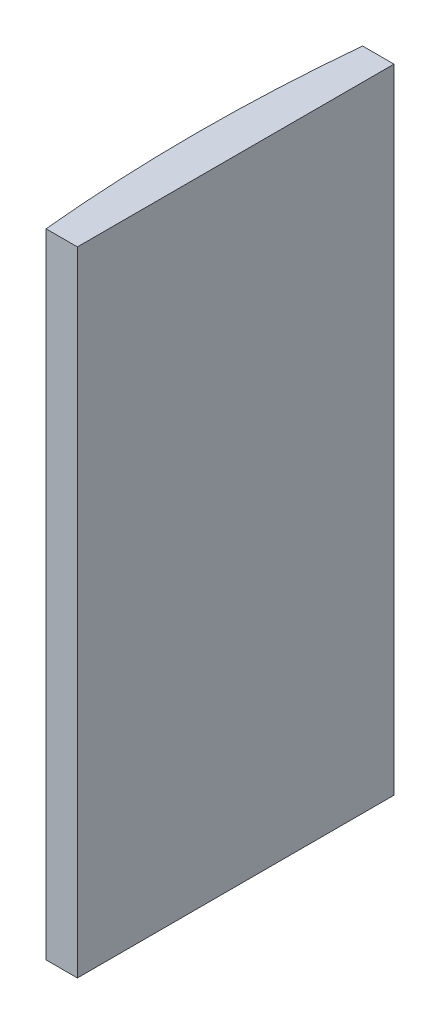
from build123d import *

# Parameters (mm, degrees)
EXTRUDE_1_DEPTH = 60


with BuildPart() as part:
    # 草图1 → 凸台-拉伸1 (new body)
    with BuildSketch(Plane(origin=(0, 0, 0), x_dir=(1, 0, 0), z_dir=(0, 1, 0))):
        with BuildLine():
            Line((-150.017753142, 15), (-147.044795665, 15))
            Line((-147.044795665, 15), (-147.044795665, -15))
            Line((-147.044795665, -15), (-150.017753142, -15))
            ThreePointArc((-150.017753142, -15), (-150.744795665, 0), (-150.017753142, 15))
        make_face()
    extrude(amount=EXTRUDE_1_DEPTH)


solid = part.part
